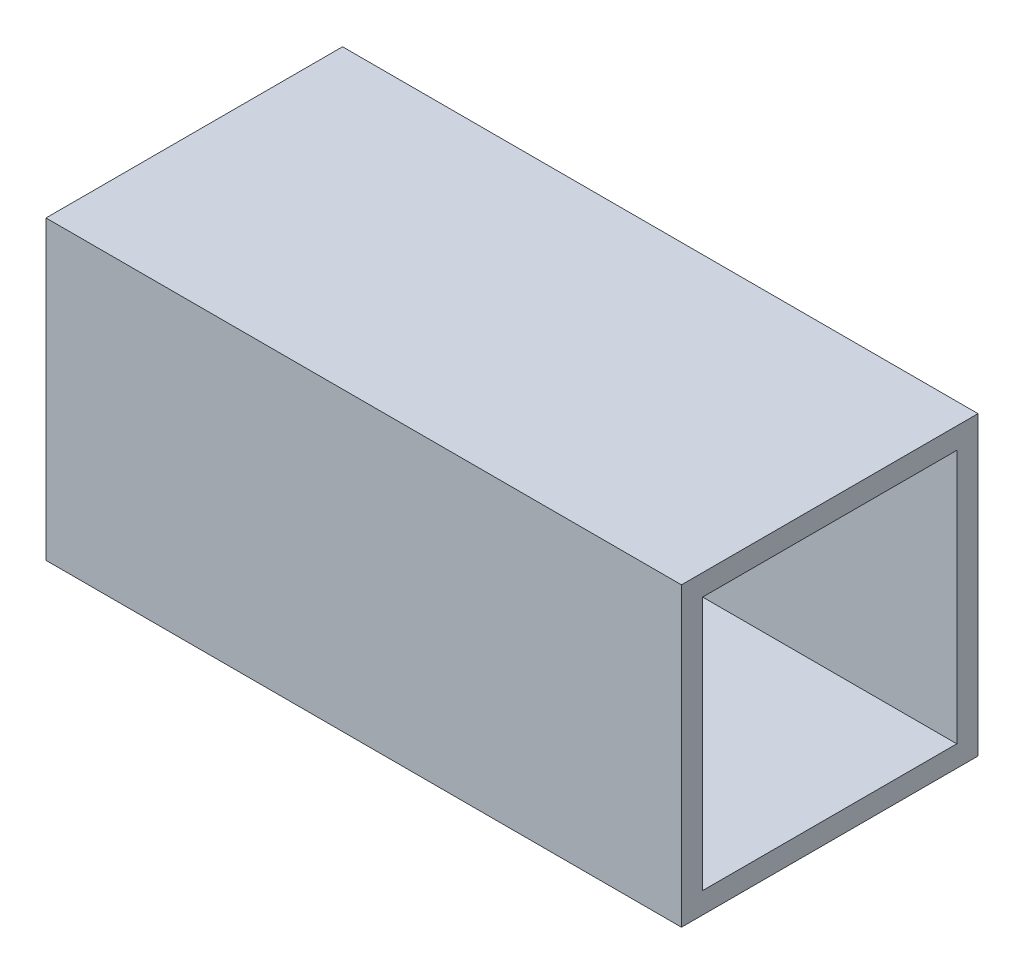
from build123d import *

# Parameters (mm, degrees)
SKETCH1_W           = 44.45
SKETCH1_H           = 44.45
SKETCH1_W_2         = 38.1
SKETCH1_H_2         = 38.1
BOSS_EXTRUDE1_DEPTH = 47.625


with BuildPart() as part:
    # Sketch1 → Boss-Extrude1 (new body, symmetric)
    with BuildSketch(Plane(origin=(0, 0, 0), x_dir=(0, 0, -1), z_dir=(1, 0, 0))):
        with Locations((22.225, 22.225)):
            Rectangle(SKETCH1_W, SKETCH1_H)
        with Locations((22.225, 22.225)):
            Rectangle(SKETCH1_W_2, SKETCH1_H_2, mode=Mode.SUBTRACT)
    extrude(amount=BOSS_EXTRUDE1_DEPTH, both=True)


solid = part.part
